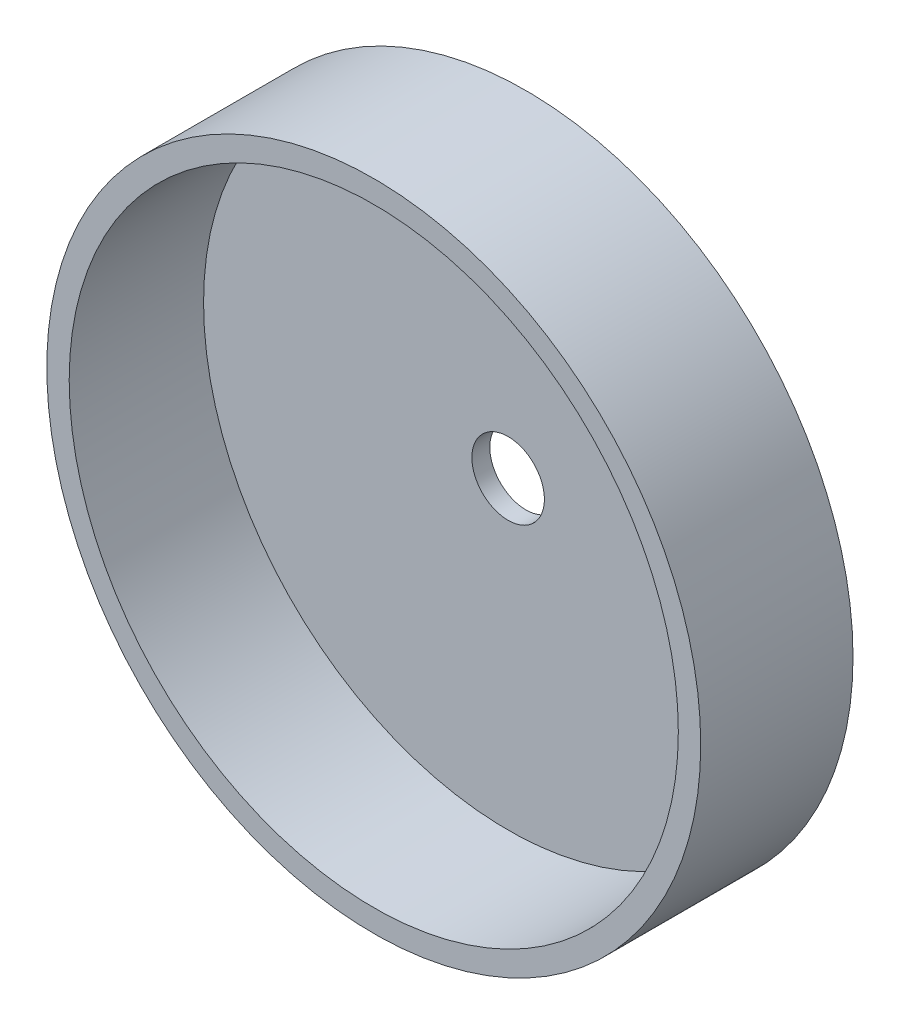
from build123d import *

# Parameters (mm, degrees)
ESQUISSE1_R                  = 34
BOSS_EXTRU_1_DEPTH           = 2
ESQUISSE2_R                  = 36.5
ESQUISSE2_R_2                = 34
BOSS_EXTRU_2_DEPTH           = 15
BOSS_EXTRU_2_DEPTH_BACK      = 2
ESQUISSE3_R                  = 4.05
ENL_V_MAT_EXTRU_1_DEPTH      = 16
ENL_V_MAT_EXTRU_1_DEPTH_BACK = 3


with BuildPart() as part:
    # Esquisse1 → Boss.-Extru.1 (new body)
    with BuildSketch(Plane.XY):
        Circle(ESQUISSE1_R)
    extrude(amount=BOSS_EXTRU_1_DEPTH)

    # Esquisse2 → Boss.-Extru.2 (add, two sides)
    with BuildSketch(Plane.XY.offset(2)) as boss_extru_2_sk:
        Circle(ESQUISSE2_R)
        Circle(ESQUISSE2_R_2, mode=Mode.SUBTRACT)
    extrude(amount=BOSS_EXTRU_2_DEPTH)
    extrude(boss_extru_2_sk.sketch, amount=-BOSS_EXTRU_2_DEPTH_BACK)

    # Esquisse3 → Enlèv. mat.-Extru.1 (cut, two sides)
    with BuildSketch(Plane.XY.offset(2)) as enl_v_mat_extru_1_sk:
        Circle(ESQUISSE3_R)
    extrude(amount=ENL_V_MAT_EXTRU_1_DEPTH, mode=Mode.SUBTRACT)
    extrude(enl_v_mat_extru_1_sk.sketch, amount=-ENL_V_MAT_EXTRU_1_DEPTH_BACK, mode=Mode.SUBTRACT)


solid = part.part
